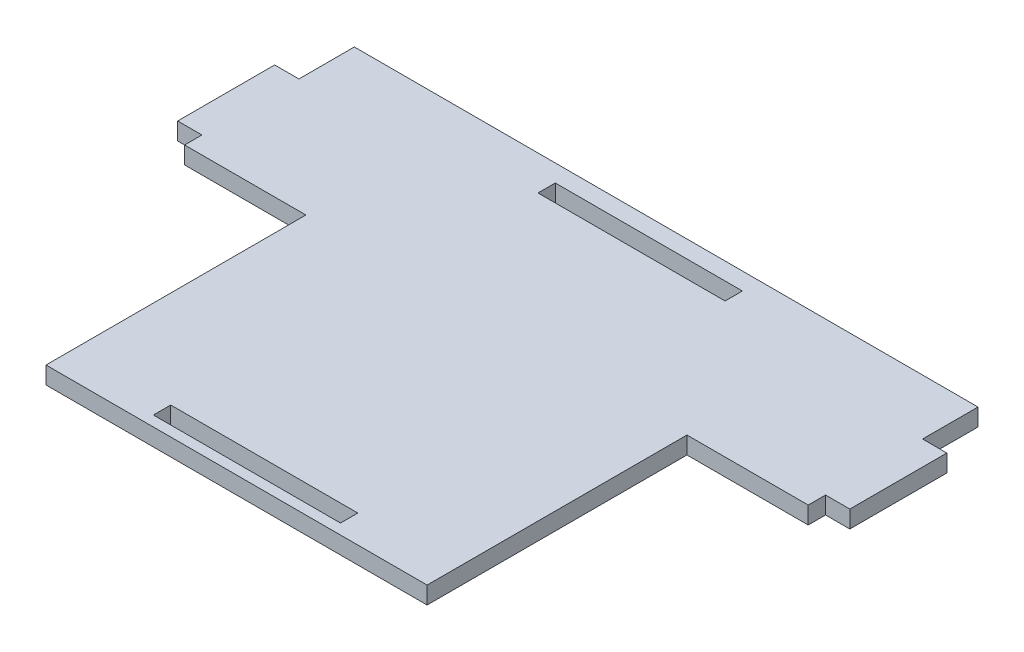
from build123d import *

# Parameters (mm, degrees)
SKETCH1_W           = 54
SKETCH1_H           = 5
BOSS_EXTRUDE1_DEPTH = 5


with BuildPart() as part:
    # Sketch1 → Boss-Extrude1 (new body)
    with BuildSketch(Plane(origin=(0, 0, 0), x_dir=(1, 0, 0), z_dir=(0, 1, 0))):
        Polygon((-90, 47), (-97, 47), (-97, 19), (-90, 19), (-90, 14), (-55, 14), (-55, -61), (55, -61), (55, 14), (90, 14), (90, 19), (97, 19), (97, 47), (90, 47), (90, 63), (-90, 63), align=None)
        with Locations((0, 55.5)):
            Rectangle(SKETCH1_W, SKETCH1_H, mode=Mode.SUBTRACT)
        with Locations((0, -55.5)):
            Rectangle(SKETCH1_W, SKETCH1_H, mode=Mode.SUBTRACT)
    extrude(amount=BOSS_EXTRUDE1_DEPTH)


solid = part.part
